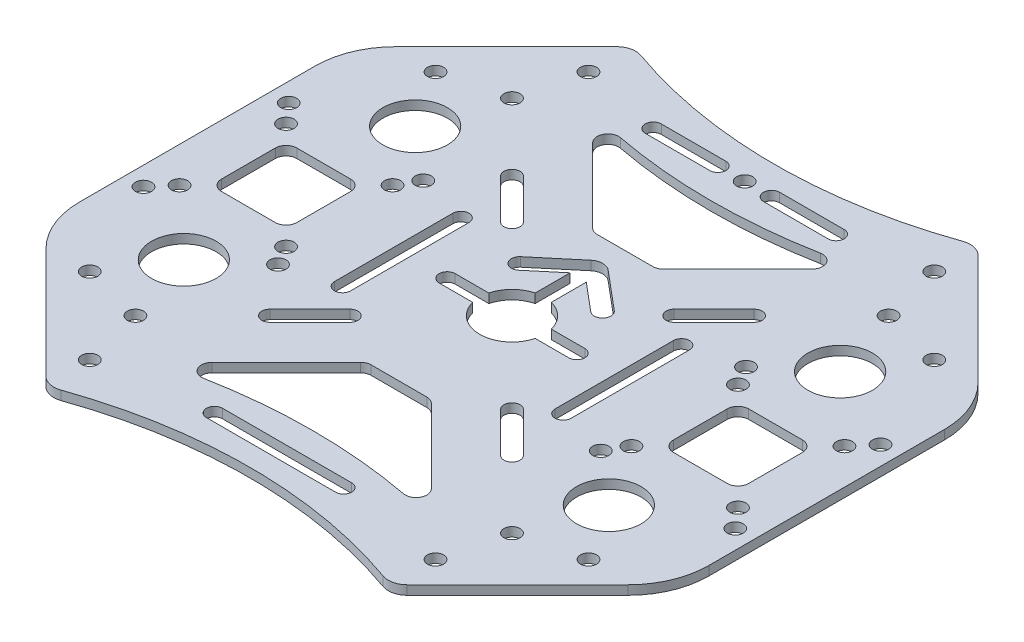
from build123d import *

# Parameters (mm, degrees)
SKETCH_1_R          = 1.5
EXTRUDE_1_DEPTH     = 1.7
FILLET_1_R          = 3.5
FILLET_2_R          = 15
SKETCH_2_R          = 1.5
SKETCH_2_R_2        = 6
CUT_EXTRUDE_1_DEPTH = 2.7


with BuildPart() as part:
    # 草圖1 → 填料-伸長1 (new body)
    with BuildSketch(Plane(origin=(0, 0, 0), x_dir=(1, 0, 0), z_dir=(0, 1, 0))):
        with BuildLine():
            Line((-31.988251141, -54.632329554), (-58.5, -28.120580695))
            Line((-58.5, -28.120580695), (-58.5, 28.120580695))
            Line((-58.5, 28.120580695), (-31.988251141, 54.632329554))
            ThreePointArc((-31.988251141, 54.632329554), (0, 48.75576142), (31.988251141, 54.632329554))
            Line((31.988251141, 54.632329554), (58.5, 28.120580695))
            Line((58.5, 28.120580695), (58.5, -28.120580695))
            Line((58.5, -28.120580695), (31.988251141, -54.632329554))
            ThreePointArc((31.988251141, -54.632329554), (0, -48.75576142), (-31.988251141, -54.632329554))
        make_face()
        with Locations((-35.001785669, 35.001785669)):
            Circle(SKETCH_1_R, mode=Mode.SUBTRACT)
        with Locations((35.001785669, -35.001785669)):
            Circle(SKETCH_1_R, mode=Mode.SUBTRACT)
        with Locations((-35.001785669, -35.001785669)):
            Circle(SKETCH_1_R, mode=Mode.SUBTRACT)
        with Locations((35.001785669, 35.001785669)):
            Circle(SKETCH_1_R, mode=Mode.SUBTRACT)
        with Locations((-32.138003205, -46.350849507)):
            Circle(SKETCH_1_R, mode=Mode.SUBTRACT)
        with Locations((-46.350849507, -32.138003205)):
            Circle(SKETCH_1_R, mode=Mode.SUBTRACT)
        with Locations((-32.138003205, 46.350849507)):
            Circle(SKETCH_1_R, mode=Mode.SUBTRACT)
        with Locations((-46.350849507, 32.138003205)):
            Circle(SKETCH_1_R, mode=Mode.SUBTRACT)
        with Locations((46.350849507, 32.138003205)):
            Circle(SKETCH_1_R, mode=Mode.SUBTRACT)
        with Locations((32.138003205, 46.350849507)):
            Circle(SKETCH_1_R, mode=Mode.SUBTRACT)
        with Locations((32.138003205, -46.350849507)):
            Circle(SKETCH_1_R, mode=Mode.SUBTRACT)
        with Locations((46.350849507, -32.138003205)):
            Circle(SKETCH_1_R, mode=Mode.SUBTRACT)
        with BuildLine():
            Line((-21.439339828, 23.560660172), (-14.014718626, 16.136038969))
            ThreePointArc((-14.014718626, 16.136038969), (-14.014718626, 14.014718626), (-16.136038969, 14.014718626))
            Line((-16.136038969, 14.014718626), (-23.560660172, 21.439339828))
            ThreePointArc((-23.560660172, 21.439339828), (-23.560660172, 23.560660172), (-21.439339828, 23.560660172))
        make_face(mode=Mode.SUBTRACT)
        with BuildLine():
            Line((21.439339828, 23.560660172), (14.014718626, 16.136038969))
            ThreePointArc((14.014718626, 16.136038969), (14.014718626, 14.014718626), (16.136038969, 14.014718626))
            Line((16.136038969, 14.014718626), (23.560660172, 21.439339828))
            ThreePointArc((23.560660172, 21.439339828), (23.560660172, 23.560660172), (21.439339828, 23.560660172))
        make_face(mode=Mode.SUBTRACT)
        with BuildLine():
            Line((21.439339828, -23.560660172), (14.014718626, -16.136038969))
            ThreePointArc((14.014718626, -16.136038969), (14.014718626, -14.014718626), (16.136038969, -14.014718626))
            Line((16.136038969, -14.014718626), (23.560660172, -21.439339828))
            ThreePointArc((23.560660172, -21.439339828), (23.560660172, -23.560660172), (21.439339828, -23.560660172))
        make_face(mode=Mode.SUBTRACT)
        with BuildLine():
            Line((-21.439339828, -23.560660172), (-14.014718626, -16.136038969))
            ThreePointArc((-14.014718626, -16.136038969), (-14.014718626, -14.014718626), (-16.136038969, -14.014718626))
            Line((-16.136038969, -14.014718626), (-23.560660172, -21.439339828))
            ThreePointArc((-23.560660172, -21.439339828), (-23.560660172, -23.560660172), (-21.439339828, -23.560660172))
        make_face(mode=Mode.SUBTRACT)
        with BuildLine():
            Line((-1.5, 5.809475019), (-1.5, 12.309475019))
            Line((-1.5, 12.309475019), (-6.701273653, 7.945088216))
            ThreePointArc((-6.701273653, 7.945088216), (-8.884963334, 8.136136308), (-8.693915243, 10.319825989))
            Line((-8.693915243, 10.319825989), (-1.606969024, 16.266479947))
            ThreePointArc((-1.606969024, 16.266479947), (0, 16.85136884), (1.606969024, 16.266479947))
            Line((1.606969024, 16.266479947), (8.693915243, 10.319825989))
            ThreePointArc((8.693915243, 10.319825989), (8.884963334, 8.136136308), (6.701273653, 7.945088216))
            Line((6.701273653, 7.945088216), (1.5, 12.309475019))
            Line((1.5, 12.309475019), (1.5, 5.809475019))
            ThreePointArc((1.5, 5.809475019), (0, -6), (-1.5, 5.809475019))
        make_face(mode=Mode.SUBTRACT)
    extrude(amount=EXTRUDE_1_DEPTH)

    # 圓角1
    fillet_1_edges = [part.edges().sort_by_distance(p)[0] for p in [
        (31.988251141, 0.85, -54.632329554),
        (31.988251141, 0.85, 54.632329554),
        (-31.988251141, 0.85, 54.632329554),
        (-31.988251141, 0.85, -54.632329554),
    ]]
    fillet(fillet_1_edges, radius=FILLET_1_R)

    # 圓角2
    fillet_2_edges = [part.edges().sort_by_distance(p)[0] for p in [
        (58.5, 0.85, -28.120580695),
        (58.5, 0.85, 28.120580695),
        (-58.5, 0.85, 28.120580695),
        (-58.5, 0.85, -28.120580695),
    ]]
    fillet(fillet_2_edges, radius=FILLET_2_R)

    # 草圖2 → 除料-伸長1 (cut, through all)
    with BuildSketch(Plane(origin=(0, 1.7, 0), x_dir=(1, 0, 0), z_dir=(0, 1, 0))):
        with Locations((0, 43.25)):
            Circle(SKETCH_2_R)
        with Locations((39.5, 21.5)):
            Circle(SKETCH_2_R_2)
        with Locations((39.5, -21.5)):
            Circle(SKETCH_2_R_2)
        with Locations((-39.5, -21.5)):
            Circle(SKETCH_2_R_2)
        with Locations((-39.5, 21.5)):
            Circle(SKETCH_2_R_2)
        with Locations((-32.100505063, 9.899494937)):
            Circle(SKETCH_2_R)
        with Locations((-32.100505063, -9.899494937)):
            Circle(SKETCH_2_R)
        with Locations((-51.899494937, 9.899494937)):
            Circle(SKETCH_2_R)
        with Locations((-51.899494937, -9.899494937)):
            Circle(SKETCH_2_R)
        with Locations((-55, 13.5)):
            Circle(SKETCH_2_R)
        with Locations((-55, -13.5)):
            Circle(SKETCH_2_R)
        with Locations((-30, 13.5)):
            Circle(SKETCH_2_R)
        with Locations((-30, -13.5)):
            Circle(SKETCH_2_R)
        with Locations((55, -13.5)):
            Circle(SKETCH_2_R)
        with Locations((51.899494937, -9.899494937)):
            Circle(SKETCH_2_R)
        with Locations((55, 13.5)):
            Circle(SKETCH_2_R)
        with Locations((51.899494937, 9.899494937)):
            Circle(SKETCH_2_R)
        with Locations((30, 13.5)):
            Circle(SKETCH_2_R)
        with Locations((32.100505063, 9.899494937)):
            Circle(SKETCH_2_R)
        with Locations((30, -13.5)):
            Circle(SKETCH_2_R)
        with Locations((32.100505063, -9.899494937)):
            Circle(SKETCH_2_R)
        with BuildLine():
            Line((37, -7), (47, -7))
            ThreePointArc((47, -7), (48.414213562, -6.414213562), (49, -5))
            Line((49, -5), (49, 5))
            ThreePointArc((49, 5), (48.414213562, 6.414213562), (47, 7))
            Line((47, 7), (37, 7))
            ThreePointArc((37, 7), (35.585786438, 6.414213562), (35, 5))
            Line((35, 5), (35, -5))
            ThreePointArc((35, -5), (35.585786438, -6.414213562), (37, -7))
        make_face()
        with BuildLine():
            Line((-37, 7), (-47, 7))
            ThreePointArc((-47, 7), (-48.414213562, 6.414213562), (-49, 5))
            Line((-49, 5), (-49, -5))
            ThreePointArc((-49, -5), (-48.414213562, -6.414213562), (-47, -7))
            Line((-47, -7), (-37, -7))
            ThreePointArc((-37, -7), (-35.585786438, -6.414213562), (-35, -5))
            Line((-35, -5), (-35, 5))
            ThreePointArc((-35, 5), (-35.585786438, 6.414213562), (-37, 7))
        make_face()
        with BuildLine():
            Line((-12.05, 1.5), (12.05, 1.5))
            ThreePointArc((12.05, 1.5), (13.55, 0), (12.05, -1.5))
            Line((12.05, -1.5), (-12.05, -1.5))
            ThreePointArc((-12.05, -1.5), (-13.55, 0), (-12.05, 1.5))
        make_face()
        with BuildLine():
            Line((-19, 11), (-19, -11))
            ThreePointArc((-19, -11), (-20.5, -12.5), (-22, -11))
            Line((-22, -11), (-22, 11))
            ThreePointArc((-22, 11), (-20.5, 12.5), (-19, 11))
        make_face()
        with BuildLine():
            Line((19, 11), (19, -11))
            ThreePointArc((19, -11), (20.5, -12.5), (22, -11))
            Line((22, -11), (22, 11))
            ThreePointArc((22, 11), (20.5, 12.5), (19, 11))
        make_face()
        with BuildLine():
            Line((-12, -41.8), (12, -41.8))
            ThreePointArc((12, -41.8), (13.5, -43.3), (12, -44.8))
            Line((12, -44.8), (-12, -44.8))
            ThreePointArc((-12, -44.8), (-13.5, -43.3), (-12, -41.8))
        make_face()
        with BuildLine():
            Line((5, 44.75), (17, 44.75))
            ThreePointArc((17, 44.75), (18.5, 43.25), (17, 41.75))
            Line((17, 41.75), (5, 41.75))
            ThreePointArc((5, 41.75), (3.5, 43.25), (5, 44.75))
        make_face()
        with BuildLine():
            Line((-5, 44.75), (-17, 44.75))
            ThreePointArc((-17, 44.75), (-18.5, 43.25), (-17, 41.75))
            Line((-17, 41.75), (-5, 41.75))
            ThreePointArc((-5, 41.75), (-3.5, 43.25), (-5, 44.75))
        make_face()
        with BuildLine():
            Line((-6.585786438, -21.585786438), (-20.360929457, -35.360929457))
            ThreePointArc((-20.360929457, -35.360929457), (-20.715022522, -37.709536765), (-18.575211661, -38.740336293))
            ThreePointArc((-18.575211661, -38.740336293), (0, -37), (18.575211661, -38.740336293))
            ThreePointArc((18.575211661, -38.740336293), (20.715022522, -37.709536765), (20.360929457, -35.360929457))
            Line((20.360929457, -35.360929457), (6.585786438, -21.585786438))
            ThreePointArc((6.585786438, -21.585786438), (5.93693974, -21.152240935), (5.171572875, -21))
            Line((5.171572875, -21), (-5.171572875, -21))
            ThreePointArc((-5.171572875, -21), (-5.93693974, -21.152240935), (-6.585786438, -21.585786438))
        make_face()
        with BuildLine():
            Line((-5.171572875, 21), (5.171572875, 21))
            ThreePointArc((5.171572875, 21), (5.93693974, 21.152240935), (6.585786438, 21.585786438))
            Line((6.585786438, 21.585786438), (20.360929457, 35.360929457))
            ThreePointArc((20.360929457, 35.360929457), (20.715022522, 37.709536765), (18.575211661, 38.740336293))
            ThreePointArc((18.575211661, 38.740336293), (0, 37), (-18.575211661, 38.740336293))
            ThreePointArc((-18.575211661, 38.740336293), (-20.715022522, 37.709536765), (-20.360929457, 35.360929457))
            Line((-20.360929457, 35.360929457), (-6.585786438, 21.585786438))
            ThreePointArc((-6.585786438, 21.585786438), (-5.93693974, 21.152240935), (-5.171572875, 21))
        make_face()
    extrude(amount=-CUT_EXTRUDE_1_DEPTH, mode=Mode.SUBTRACT)


solid = part.part
